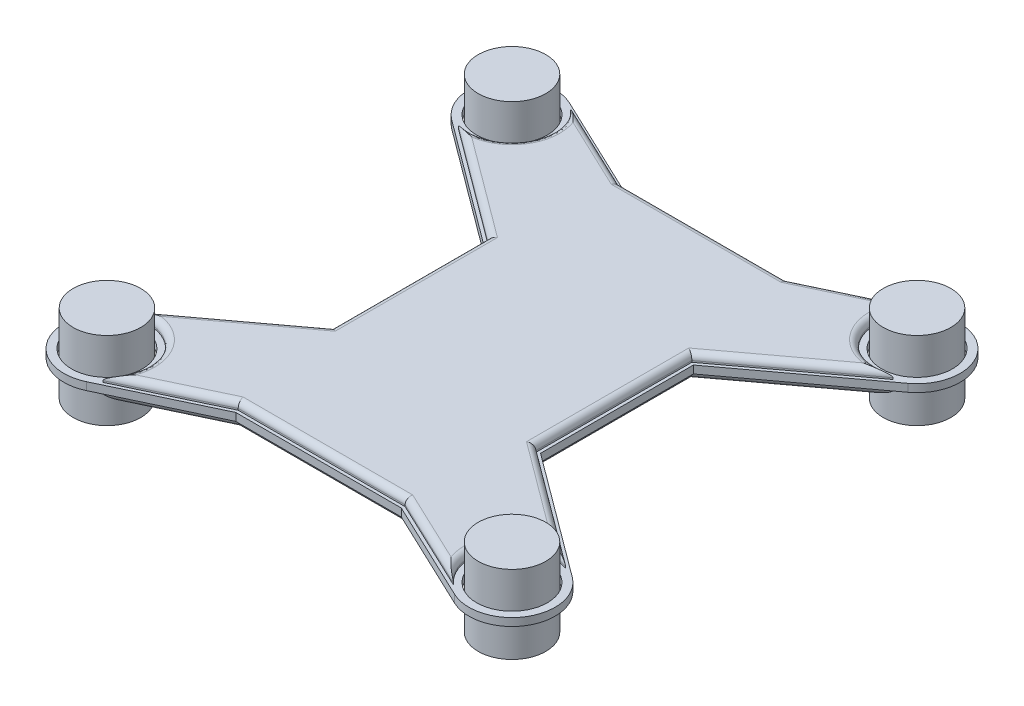
from build123d import *

# Parameters (mm, degrees)
SKETCH1_R             = 13.85
BOSS_EXTRUDE2_DEPTH   = 32
BOSS_EXTRUDE2_2_DEPTH = 32
BOSS_EXTRUDE2_3_DEPTH = 32
BOSS_EXTRUDE2_4_DEPTH = 32
SKETCH2_R             = 14.485
SKETCH2_W             = 9.100330899
SKETCH2_H             = 62.655558446
SKETCH2_W_2           = 67.825440706
SKETCH2_H_2           = 47.948339229
BOSS_EXTRUDE3_DEPTH   = 1.5875
BOSS_EXTRUDE4_DEPTH   = 3.175
FILLET1_R             = 2.54
FILLET2_R             = 2.54


with BuildPart() as part:
    # Sketch1 → Boss-Extrude2 (new body)
    with BuildSketch(Plane(origin=(0, 0, 0), x_dir=(1, 0, 0), z_dir=(0, 1, 0))):
        with Locations((-82.99781005, 82.99781005)):
            Circle(SKETCH1_R)
    extrude(amount=BOSS_EXTRUDE2_DEPTH)


with BuildPart() as body_2:
    # Sketch1 → Boss-Extrude2 2 (new body)
    with BuildSketch(Plane(origin=(0, 0, 0), x_dir=(1, 0, 0), z_dir=(0, 1, 0))):
        with Locations((82.99781005, 82.99781005)):
            Circle(SKETCH1_R)
    extrude(amount=BOSS_EXTRUDE2_2_DEPTH)


with BuildPart() as body_3:
    # Sketch1 → Boss-Extrude2 3 (new body)
    with BuildSketch(Plane(origin=(0, 0, 0), x_dir=(1, 0, 0), z_dir=(0, 1, 0))):
        with Locations((82.99781005, -82.99781005)):
            Circle(SKETCH1_R)
    extrude(amount=BOSS_EXTRUDE2_3_DEPTH)


with BuildPart() as body_4:
    # Sketch1 → Boss-Extrude2 4 (new body)
    with BuildSketch(Plane(origin=(0, 0, 0), x_dir=(1, 0, 0), z_dir=(0, 1, 0))):
        with Locations((-82.99781005, -82.99781005)):
            Circle(SKETCH1_R)
    extrude(amount=BOSS_EXTRUDE2_4_DEPTH)


with BuildPart() as body_5:
    # Sketch2 → Boss-Extrude3 (new body, symmetric)
    with BuildSketch(Plane(origin=(0, 16, 0), x_dir=(1, 0, 0), z_dir=(0, 1, 0))):
        with BuildLine():
            Line((-93.523015432, 68.816990216), (-43.013051252, 31.327779223))
            Line((-43.013051252, 31.327779223), (-33.912720353, 31.327779223))
            Line((-33.912720353, 31.327779223), (-33.912720353, 79.276118452))
            Line((-33.912720353, 79.276118452), (-75.434062334, 98.956046794))
            ThreePointArc((-75.434062334, 98.956046794), (-98.139911646, 92.085843873), (-93.523015432, 68.816990216))
        make_face()
        with Locations((-82.99781005, 82.99781005)):
            Circle(SKETCH2_R, mode=Mode.SUBTRACT)
        with Locations((-38.462885803, 0)):
            Rectangle(SKETCH2_W, SKETCH2_H)
        with BuildLine():
            Line((-43.013051252, -31.327779223), (-93.523015432, -68.816990216))
            ThreePointArc((-93.523015432, -68.816990216), (-98.139911646, -92.085843873), (-75.434062334, -98.956046794))
            Line((-75.434062334, -98.956046794), (-33.912720353, -79.276118452))
            Line((-33.912720353, -79.276118452), (-33.912720353, -31.327779223))
            Line((-33.912720353, -31.327779223), (-43.013051252, -31.327779223))
        make_face()
        with Locations((-82.99781005, -82.99781005)):
            Circle(SKETCH2_R, mode=Mode.SUBTRACT)
        with Locations((0, -55.301948838)):
            Rectangle(SKETCH2_W_2, SKETCH2_H_2)
        Rectangle(SKETCH2_W_2, SKETCH2_H)
        with Locations((0, 55.301948838)):
            Rectangle(SKETCH2_W_2, SKETCH2_H_2)
        with BuildLine():
            Line((33.912720353, 79.276118452), (33.912720353, 31.327779223))
            Line((33.912720353, 31.327779223), (43.013051252, 31.327779223))
            Line((43.013051252, 31.327779223), (93.523015432, 68.816990216))
            ThreePointArc((93.523015432, 68.816990216), (98.139911646, 92.085843873), (75.434062334, 98.956046794))
            Line((75.434062334, 98.956046794), (33.912720353, 79.276118452))
        make_face()
        with Locations((82.99781005, 82.99781005)):
            Circle(SKETCH2_R, mode=Mode.SUBTRACT)
        with Locations((38.462885803, 0)):
            Rectangle(SKETCH2_W, SKETCH2_H)
        with BuildLine():
            Line((43.013051252, -31.327779223), (33.912720353, -31.327779223))
            Line((33.912720353, -31.327779223), (33.912720353, -79.276118452))
            Line((33.912720353, -79.276118452), (75.434062334, -98.956046794))
            ThreePointArc((75.434062334, -98.956046794), (98.139911646, -92.085843873), (93.523015432, -68.816990216))
            Line((93.523015432, -68.816990216), (43.013051252, -31.327779223))
        make_face()
        with Locations((82.99781005, -82.99781005)):
            Circle(SKETCH2_R, mode=Mode.SUBTRACT)
    extrude(amount=BOSS_EXTRUDE3_DEPTH, both=True)

    # Sketch3 → Boss-Extrude4 (add)
    with BuildSketch(Plane(origin=(0, 17.5875, 0), x_dir=(1, 0, 0), z_dir=(0, 1, 0))):
        with BuildLine():
            Line((-34.198456922, 78.006118452), (-71.815524559, 95.835532441))
            ThreePointArc((-71.815524559, 95.835532441), (-68.400172458, 74.236554333), (-89.067243597, 67.091440212))
            Line((-89.067243597, 67.091440212), (-41.743051252, 31.966754208))
            Line((-41.743051252, 31.966754208), (-41.743051252, -31.966754208))
            Line((-41.743051252, -31.966754208), (-89.067243597, -67.091440212))
            ThreePointArc((-89.067243597, -67.091440212), (-68.400172458, -74.236554333), (-71.815524559, -95.835532441))
            Line((-71.815524559, -95.835532441), (-34.198456922, -78.006118452))
            Line((-34.198456922, -78.006118452), (34.198456922, -78.006118452))
            Line((34.198456922, -78.006118452), (71.815524559, -95.835532441))
            ThreePointArc((71.815524559, -95.835532441), (68.400172458, -74.236554333), (89.067243597, -67.091440212))
            Line((89.067243597, -67.091440212), (41.743051252, -31.966754208))
            Line((41.743051252, -31.966754208), (41.743051252, 31.966754208))
            Line((41.743051252, 31.966754208), (89.067243597, 67.091440212))
            ThreePointArc((89.067243597, 67.091440212), (68.400172458, 74.236554333), (71.815524559, 95.835532441))
            Line((71.815524559, 95.835532441), (34.198456922, 78.006118452))
            Line((34.198456922, 78.006118452), (-34.198456922, 78.006118452))
        make_face()
    boss_extrude4 = extrude(amount=BOSS_EXTRUDE4_DEPTH)

    # Fillet1
    fillet1_edges = [body_5.edges().sort_by_distance(p)[0] for p in [
        (68.400172458, 20.7625, 74.236554333),
        (65.405147425, 20.7625, 49.52909721),
        (41.743051252, 20.7625, 0),
        (65.405147425, 20.7625, -49.52909721),
        (68.400172458, 20.7625, -74.236554333),
        (53.00699074, 20.7625, -86.920825447),
        (0, 20.7625, -78.006118452),
        (-53.00699074, 20.7625, -86.920825447),
        (-68.400172458, 20.7625, -74.236554333),
        (-65.405147425, 20.7625, -49.52909721),
        (-41.743051252, 20.7625, 0),
        (-65.405147425, 20.7625, 49.52909721),
        (-68.400172458, 20.7625, 74.236554333),
        (-53.00699074, 20.7625, 86.920825447),
        (0, 20.7625, 78.006118452),
        (53.00699074, 20.7625, 86.920825447),
    ]]
    fillet(fillet1_edges, radius=FILLET1_R)

    # Mirror1: Boss-Extrude4 across plane
    add(boss_extrude4.mirror(Plane.ZX.offset(16)))

    # Fillet2
    fillet2_edges = [body_5.edges().sort_by_distance(p)[0] for p in [
        (68.400172458, 11.2375, 74.236554333),
        (53.00699074, 11.2375, 86.920825447),
        (0, 11.2375, 78.006118452),
        (-53.00699074, 11.2375, 86.920825447),
        (-68.400172458, 11.2375, 74.236554333),
        (-65.405147425, 11.2375, 49.52909721),
        (-41.743051252, 11.2375, 0),
        (-65.405147425, 11.2375, -49.52909721),
        (-68.400172458, 11.2375, -74.236554333),
        (-53.00699074, 11.2375, -86.920825447),
        (0, 11.2375, -78.006118452),
        (53.00699074, 11.2375, -86.920825447),
        (68.400172458, 11.2375, -74.236554333),
        (65.405147425, 11.2375, -49.52909721),
        (41.743051252, 11.2375, 0),
        (65.405147425, 11.2375, 49.52909721),
    ]]
    fillet(fillet2_edges, radius=FILLET2_R)


solid = Compound([part.part, body_2.part, body_3.part, body_4.part, body_5.part])
